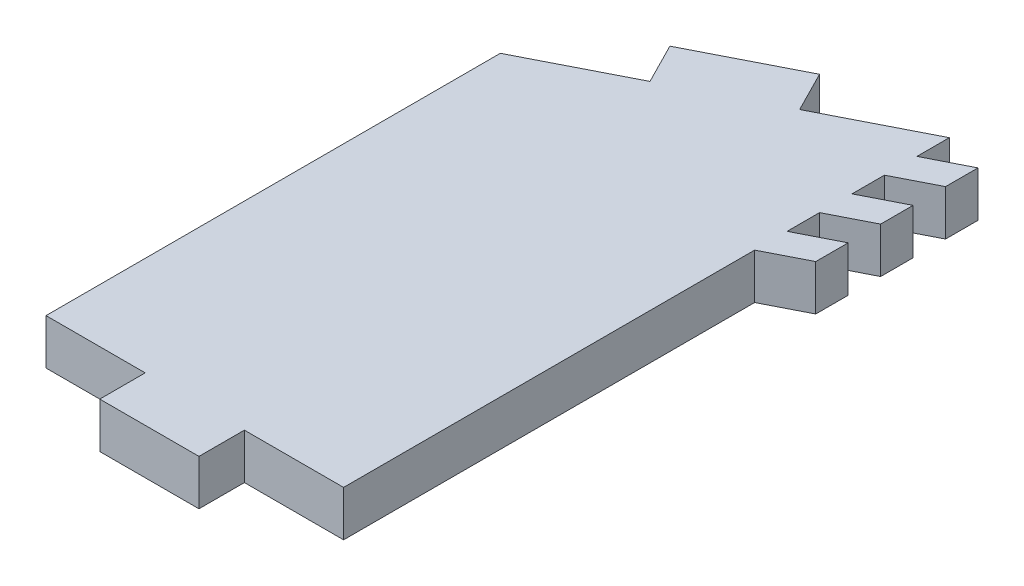
from build123d import *

# Parameters (mm, degrees)
BOSS_EXTRUDE1_DEPTH = 3
SKETCH2_W           = 6.55
SKETCH2_H           = 3
BOSS_EXTRUDE2_DEPTH = 3


with BuildPart() as part:
    # Sketch1 → Boss-Extrude1 (new body)
    with BuildSketch(Plane(origin=(0, 0, 0), x_dir=(1, 0, 0), z_dir=(0, 1, 0))):
        Polygon((0, 30), (19.65, 40), (19.65, 30), (19.65, 0), (0, 0), align=None)
    extrude(amount=BOSS_EXTRUDE1_DEPTH)

    # Sketch2 → Boss-Extrude2 (add)
    with BuildSketch(Plane.XZ):
        Polygon((13.099461063, -36.666392399), (11.7388049, -39.340081761), (5.188265963, -36.006474159), (6.548922127, -33.332784797), align=None)
        Polygon((19.65, -27.142857143), (22.323732333, -28.503428866), (22.323732333, -30.646285866), (19.65, -29.285714143), align=None)
        Polygon((19.65, -31.428571143), (22.323732333, -32.789142866), (22.323732333, -34.931999866), (19.65, -33.571428143), align=None)
        Polygon((19.65, -35.714285143), (22.323732333, -37.074856866), (22.323732333, -39.217713866), (19.65, -37.857142143), align=None)
        with Locations((9.825, 1.5)):
            Rectangle(SKETCH2_W, SKETCH2_H)
    extrude(amount=-BOSS_EXTRUDE2_DEPTH)


solid = part.part
